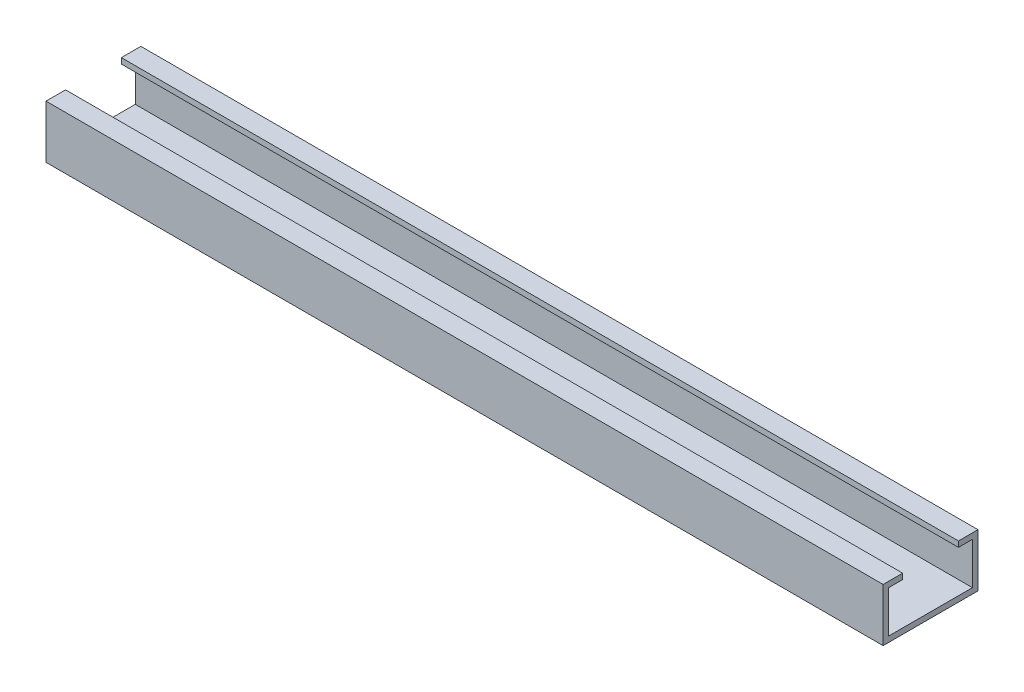
from build123d import *

# Parameters (mm, degrees)
EXTRUDE_1_DEPTH = 300


with BuildPart() as part:
    # Эскиз1 → Вытянуть-Тонкостенный1 (new body)
    with BuildSketch(Plane(origin=(0, 0, 0), x_dir=(0, 0, -1), z_dir=(1, 0, 0))):
        Polygon((-10, 15), (-15, 15), (-15, 0), (15, 0), (15, 15), (10, 15), (10, 17), (17, 17), (17, -2), (-17, -2), (-17, 17), (-10, 17), align=None)
    extrude(amount=EXTRUDE_1_DEPTH)


solid = part.part
